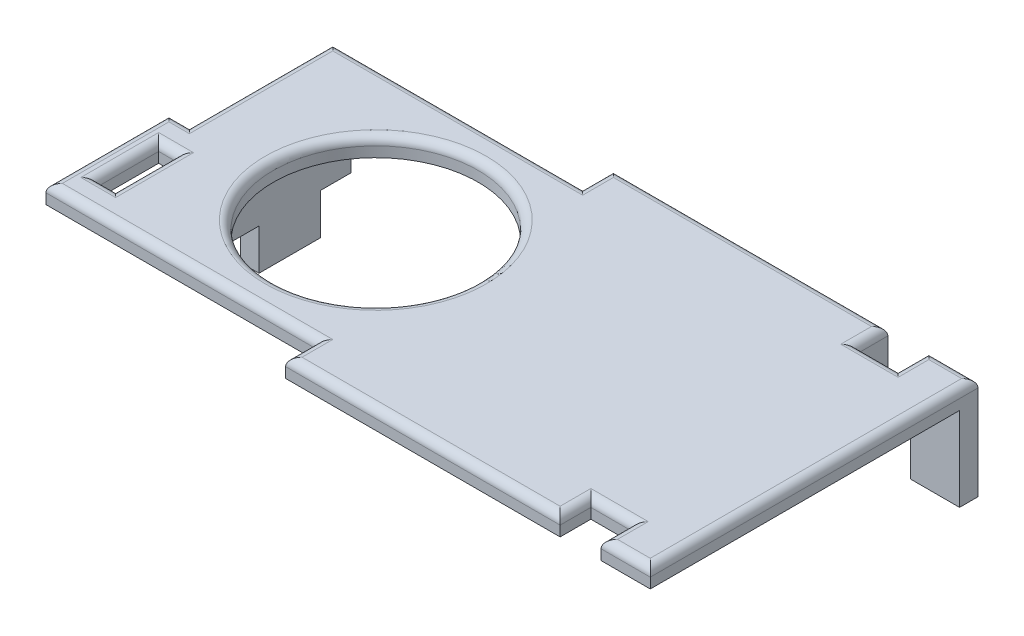
from build123d import *

# Parameters (mm, degrees)
BOSS_EXTRUDE1_DEPTH = 1.143
SKETCH3_W           = 9.017
SKETCH3_H           = 1.143
SKETCH3_W_2         = 3.048
BOSS_EXTRUDE2_DEPTH = 6.35
BOSS_EXTRUDE4_DEPTH = 1.143
SKETCH5_R           = 6.35
SKETCH5_W           = 1.143
SKETCH5_H           = 3.81
CUT_EXTRUDE2_DEPTH  = 2.143
FILLET1_R           = 0.508


with BuildPart() as part:
    # Sketch2 → Boss-Extrude1 (new body)
    with BuildSketch(Plane(origin=(0, 0, 0), x_dir=(1, 0, 0), z_dir=(0, 1, 0))):
        Polygon((0, -10.16), (0, 10.16), (-3.048, 10.16), (-3.048, 8.255), (-5.588, 8.255), (-5.588, 10.16), (-22.606, 10.16), (-22.606, 8.255), (-38.1, 8.255), (-38.1, -0.635), (-39.37, -0.635), (-39.37, -8.255), (-38.1, -8.255), (-22.606, -8.255), (-22.606, -10.16), (-5.588, -10.16), (-5.588, -8.255), (-3.048, -8.255), (-3.048, -10.16), align=None)
    extrude(amount=BOSS_EXTRUDE1_DEPTH)

    # Sketch3 → Boss-Extrude2 (add)
    with BuildSketch(Plane(origin=(0, 1.143, 0), x_dir=(1, 0, 0), z_dir=(0, 1, 0))):
        with Locations((-10.0965, 9.5885)):
            Rectangle(SKETCH3_W, SKETCH3_H)
        with Locations((-1.524, 9.5885)):
            Rectangle(SKETCH3_W_2, SKETCH3_H)
    extrude(amount=-BOSS_EXTRUDE2_DEPTH)

    # Sketch4 → Boss-Extrude4 (add)
    with BuildSketch(Plane.ZY.offset(38.1)):
        Polygon((-8.255, 1.143), (-0.635, 1.143), (-0.635, -5.334), (-2.54, -5.334), (-2.54, -7.874), (-6.35, -7.874), (-6.35, -5.334), (-8.255, -5.334), align=None)
    extrude(amount=-BOSS_EXTRUDE4_DEPTH)

    # Sketch5 → Cut-Extrude2 (cut, through all)
    with BuildSketch(Plane(origin=(0, 0, 0), x_dir=(1, 0, 0), z_dir=(0, 1, 0))):
        with Locations((-27.178, 0)):
            Circle(SKETCH5_R)
        with Locations((-37.5285, -4.445)):
            Rectangle(SKETCH5_W, SKETCH5_H)
    extrude(amount=CUT_EXTRUDE2_DEPTH, mode=Mode.SUBTRACT)

    # Fillet1
    fillet1_edges = [part.edges().sort_by_distance(p)[0] for p in [
        (-4.318, 1.143, -8.255),
        (-33.528, 1.143, 0),
        (-38.1, 1.143, 4.445),
        (-37.5285, 1.143, 6.35),
        (-36.957, 1.143, 4.445),
        (-37.5285, 1.143, 2.54),
        (-5.588, 1.143, -9.2075),
        (-14.097, 1.143, -10.16),
        (-22.606, 1.143, -9.2075),
        (-30.353, 1.143, -8.255),
        (-38.1, 1.143, -3.81),
        (-38.735, 1.143, 0.635),
        (-39.37, 1.143, 4.445),
        (-30.988, 1.143, 8.255),
        (-1.524, 1.143, -10.16),
        (-22.606, 1.143, 9.2075),
        (-14.097, 1.143, 10.16),
        (-5.588, 1.143, 9.2075),
        (-4.318, 1.143, 8.255),
        (-3.048, 1.143, 9.2075),
        (-1.524, 1.143, 10.16),
        (0, 1.143, 0),
        (-3.048, 1.143, -9.2075),
    ]]
    fillet(fillet1_edges, radius=FILLET1_R)


solid = part.part
